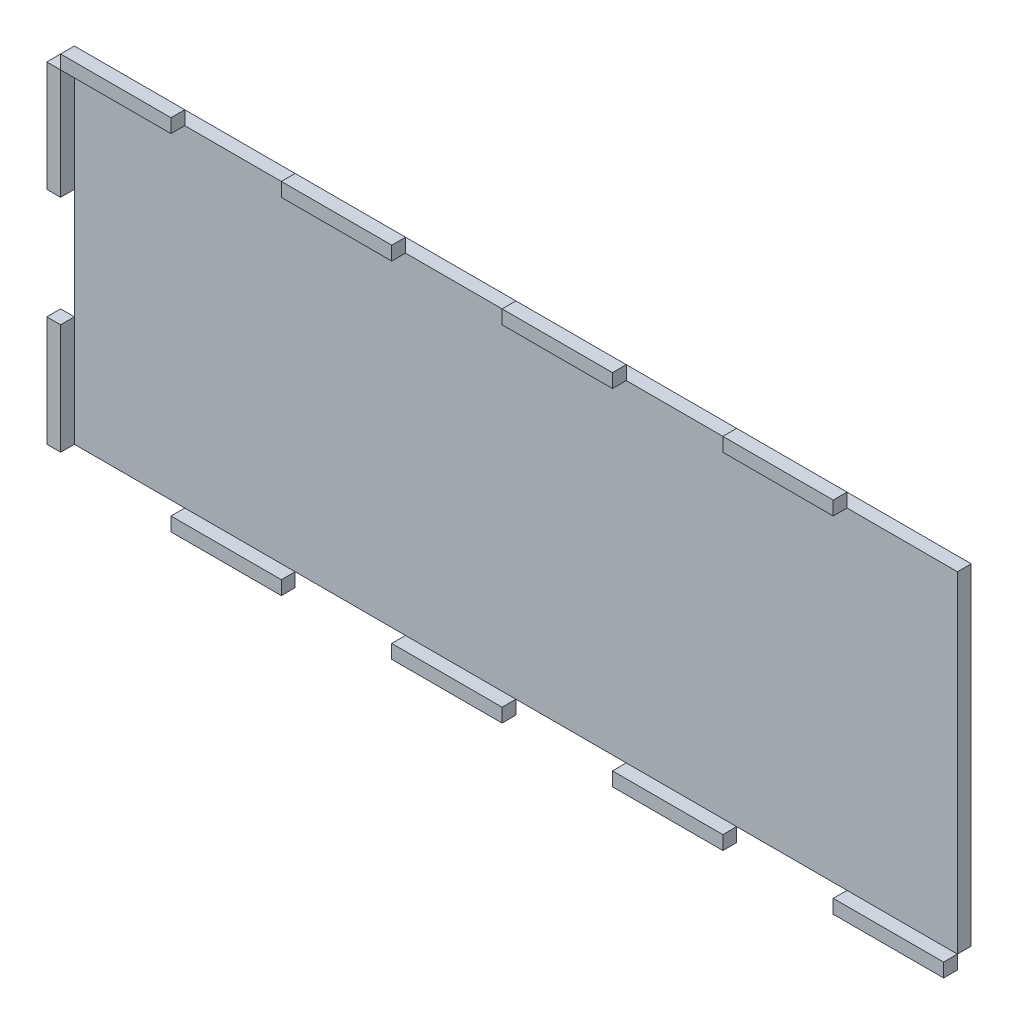
from build123d import *

# Parameters (mm, degrees)
SKETCH1_W             = 203.2
SKETCH1_H             = 76.2
BOSS_EXTRUDE1_DEPTH   = 3.175
SKETCH2_W             = 25.4
SKETCH2_H             = 3.175
BOSS_EXTRUDE2_DEPTH   = 3.175
BOSS_EXTRUDE2_2_DEPTH = 3.175
BOSS_EXTRUDE2_3_DEPTH = 3.175
BOSS_EXTRUDE2_4_DEPTH = 3.175
SKETCH3_W             = 25.4
SKETCH3_H             = 3.175
BOSS_EXTRUDE3_DEPTH   = 3.175
BOSS_EXTRUDE3_2_DEPTH = 3.175
BOSS_EXTRUDE3_3_DEPTH = 3.175
BOSS_EXTRUDE3_4_DEPTH = 3.175
SKETCH4_W             = 3.175
SKETCH4_H             = 25.4
BOSS_EXTRUDE4_DEPTH   = 3.175
BOSS_EXTRUDE4_2_DEPTH = 3.175


with BuildPart() as part:
    # Sketch1 → Boss-Extrude1 (new body)
    with BuildSketch(Plane.XY):
        Rectangle(SKETCH1_W, SKETCH1_H)
    extrude(amount=BOSS_EXTRUDE1_DEPTH)


with BuildPart() as body_2:
    # Sketch2 → Boss-Extrude2 (new body)
    with BuildSketch(Plane.XY.offset(3.175)):
        with Locations((-38.1, 39.6875)):
            Rectangle(SKETCH2_W, SKETCH2_H)
    extrude(amount=BOSS_EXTRUDE2_DEPTH)


with BuildPart() as body_3:
    # Sketch2 → Boss-Extrude2 2 (new body)
    with BuildSketch(Plane.XY.offset(3.175)):
        with Locations((-88.9, 39.6875)):
            Rectangle(SKETCH2_W, SKETCH2_H)
    extrude(amount=BOSS_EXTRUDE2_2_DEPTH)


with BuildPart() as body_4:
    # Sketch2 → Boss-Extrude2 3 (new body)
    with BuildSketch(Plane.XY.offset(3.175)):
        with Locations((12.7, 39.6875)):
            Rectangle(SKETCH2_W, SKETCH2_H)
    extrude(amount=BOSS_EXTRUDE2_3_DEPTH)


with BuildPart() as body_5:
    # Sketch2 → Boss-Extrude2 4 (new body)
    with BuildSketch(Plane.XY.offset(3.175)):
        with Locations((63.5, 39.6875)):
            Rectangle(SKETCH2_W, SKETCH2_H)
    extrude(amount=BOSS_EXTRUDE2_4_DEPTH)


with BuildPart() as body_6:
    # Sketch3 → Boss-Extrude3 (new body)
    with BuildSketch(Plane.XY.offset(3.175)):
        with Locations((38.1, -39.6875)):
            Rectangle(SKETCH3_W, SKETCH3_H)
    extrude(amount=BOSS_EXTRUDE3_DEPTH)


with BuildPart() as body_7:
    # Sketch3 → Boss-Extrude3 2 (new body)
    with BuildSketch(Plane.XY.offset(3.175)):
        with Locations((88.9, -39.6875)):
            Rectangle(SKETCH3_W, SKETCH3_H)
    extrude(amount=BOSS_EXTRUDE3_2_DEPTH)


with BuildPart() as body_8:
    # Sketch3 → Boss-Extrude3 3 (new body)
    with BuildSketch(Plane.XY.offset(3.175)):
        with Locations((-12.7, -39.6875)):
            Rectangle(SKETCH3_W, SKETCH3_H)
    extrude(amount=BOSS_EXTRUDE3_3_DEPTH)


with BuildPart() as body_9:
    # Sketch3 → Boss-Extrude3 4 (new body)
    with BuildSketch(Plane.XY.offset(3.175)):
        with Locations((-63.5, -39.6875)):
            Rectangle(SKETCH3_W, SKETCH3_H)
    extrude(amount=BOSS_EXTRUDE3_4_DEPTH)


with BuildPart() as body_10:
    # Sketch4 → Boss-Extrude4 (new body)
    with BuildSketch(Plane.XY.offset(3.175)):
        with Locations((-103.1875, -25.4)):
            Rectangle(SKETCH4_W, SKETCH4_H)
    extrude(amount=BOSS_EXTRUDE4_DEPTH)


with BuildPart() as body_11:
    # Sketch4 → Boss-Extrude4 2 (new body)
    with BuildSketch(Plane.XY.offset(3.175)):
        with Locations((-103.1875, 25.4)):
            Rectangle(SKETCH4_W, SKETCH4_H)
    extrude(amount=BOSS_EXTRUDE4_2_DEPTH)


solid = Compound([part.part, body_2.part, body_3.part, body_4.part, body_5.part, body_6.part, body_7.part, body_8.part, body_9.part, body_10.part, body_11.part])
